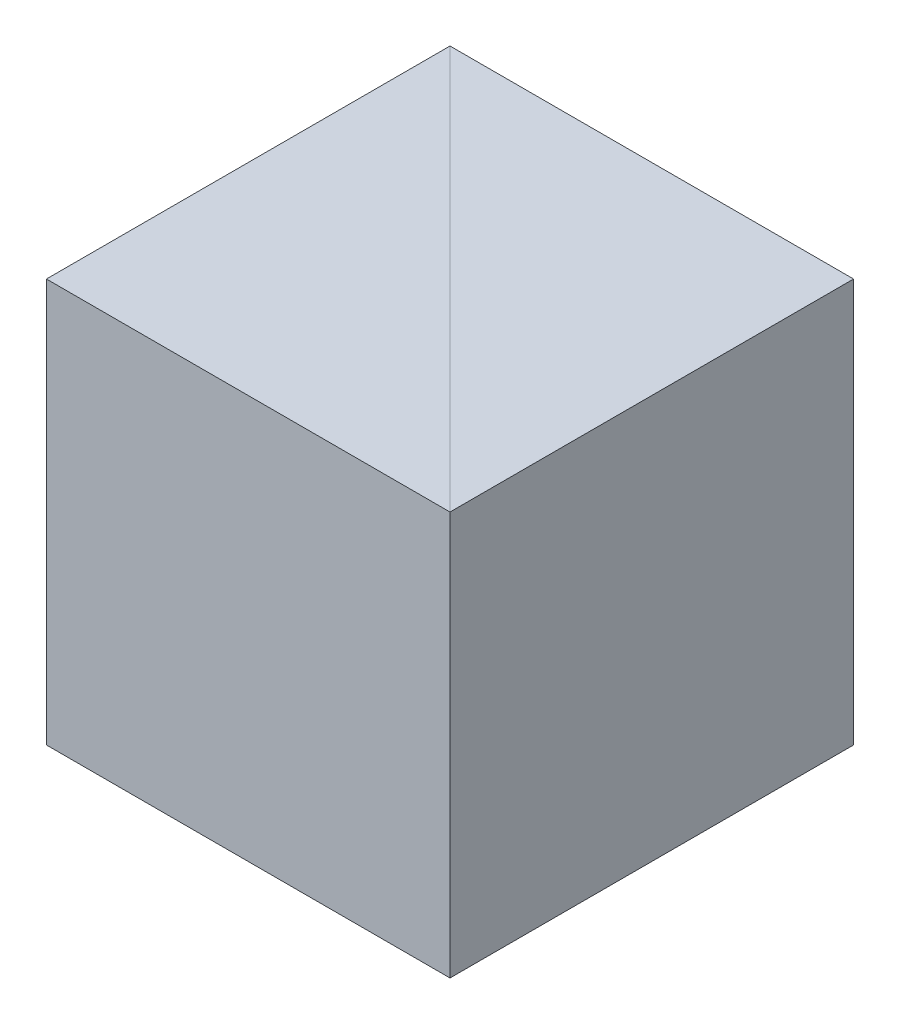
from build123d import *

# Parameters (mm, degrees)
EXTRUDE_1_DEPTH = 25.4
EXTRUDE_2_DEPTH = 25.4


with BuildPart() as part:
    # 草图1 → 凸台-拉伸1 (new body)
    with BuildSketch(Plane(origin=(0, 0, 0), x_dir=(1, 0, 0), z_dir=(0, 1, 0))):
        Polygon((0, 0), (0, 25.4), (25.4, 0), align=None)
    extrude(amount=EXTRUDE_1_DEPTH)


with BuildPart() as body_2:
    # 草图2 → 凸台-拉伸2 (new body)
    with BuildSketch(Plane.XZ):
        Polygon((0, -25.4), (25.4, -25.4), (25.4, 0), align=None)
    extrude(amount=-EXTRUDE_2_DEPTH)


solid = Compound([part.part, body_2.part])
